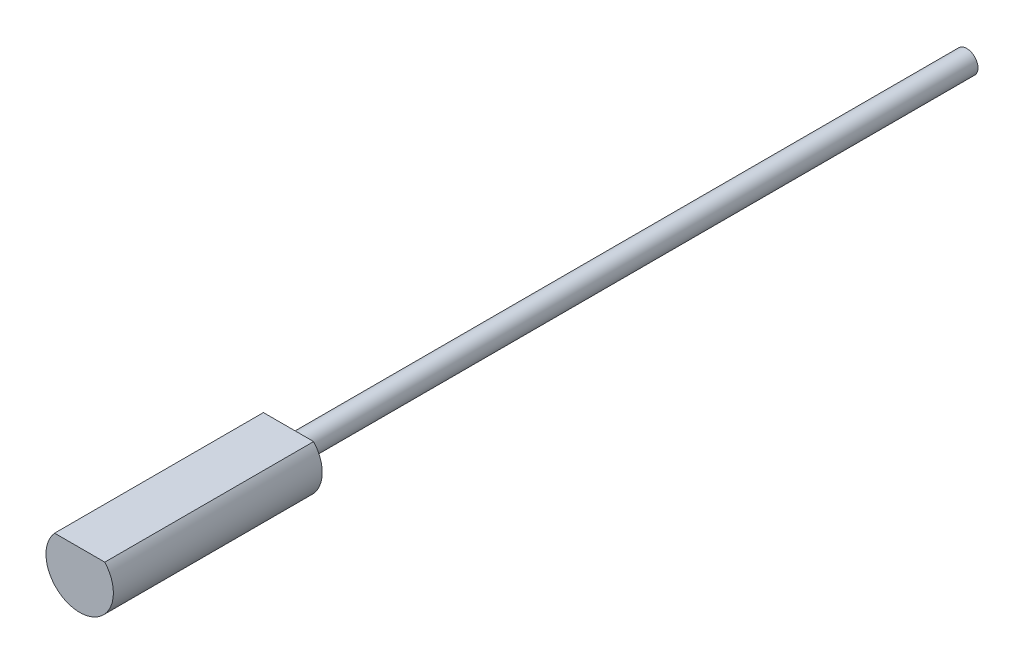
from build123d import *

# Parameters (mm, degrees)
SKETCH1_R           = 0.5
BOSS_EXTRUDE1_DEPTH = 30.2
SKETCH2_R           = 0.5
BOSS_EXTRUDE2_DEPTH = 9.3


with BuildPart() as part:
    # Sketch1 → Boss-Extrude1 (new body)
    with BuildSketch(Plane.XY):
        Circle(SKETCH1_R)
    extrude(amount=BOSS_EXTRUDE1_DEPTH)

    # Sketch2 → Boss-Extrude2 (add)
    with BuildSketch(Plane.XY.offset(30.2)):
        with BuildLine():
            Line((1.118033989, 1), (-1.118033989, 1))
            ThreePointArc((-1.118033989, 1), (0, -1.5), (1.118033989, 1))
        make_face()
        Circle(SKETCH2_R, mode=Mode.SUBTRACT)
        Circle(SKETCH2_R)
    extrude(amount=BOSS_EXTRUDE2_DEPTH)


solid = part.part
